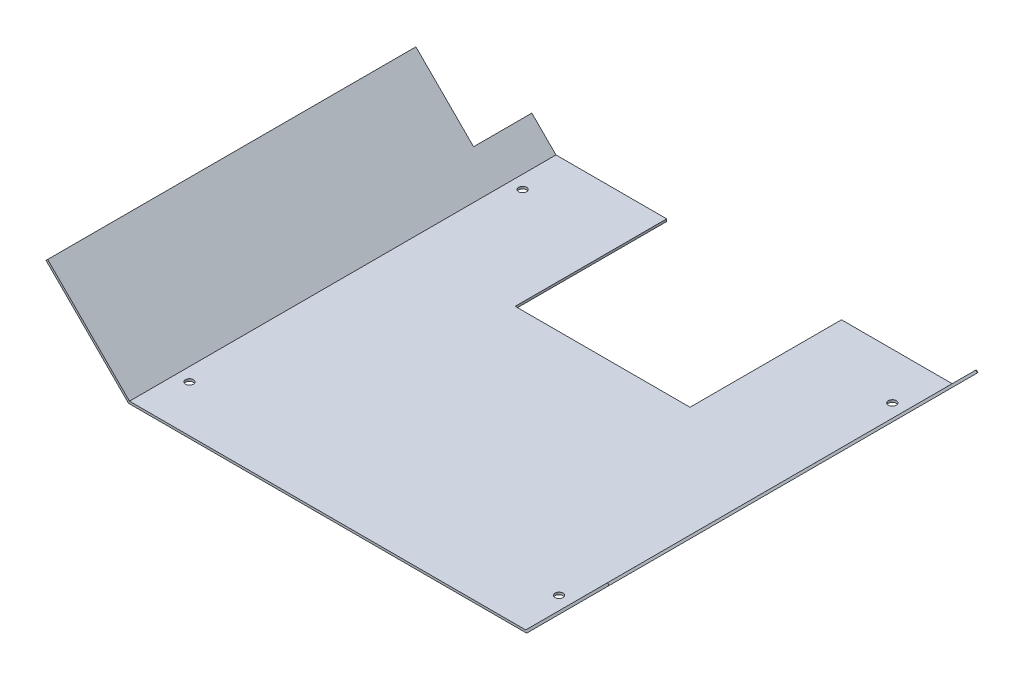
from build123d import *

# Parameters (mm, degrees)
EXTRU_MINCE1_DEPTH      = 183
ESQUISSE8_W             = 75
ESQUISSE8_H             = 65
ENL_V_MAT_EXTRU_2_DEPTH = 1
D_GAGEMENT_M32_D        = 3.4
ENL_V_MAT_EXTRU_3_REACH = 173.369
ESQUISSE15_W            = 25
ESQUISSE15_H            = 35
ENL_V_MAT_EXTRU_4_REACH = 173.364
ESQUISSE16_W            = 35
ESQUISSE16_H            = 25


with BuildPart() as part:
    # Esquisse2 → Extru.-Mince1 (new body)
    with BuildSketch(Plane.XY):
        Polygon((-59.170699115, 35.114), (-24.057682042, 0), (145.942317958, 0), (181.056317958, 35.113017073), (181.763414842, 34.405900395), (146.356523321, -1), (-24.471903803, -1), (-59.877815794, 34.406903116), align=None)
    extrude(amount=EXTRU_MINCE1_DEPTH)

    # Esquisse8 → Enlèv. mat.-Extru.2 (cut)
    with BuildSketch(Plane(origin=(0, 0, 0), x_dir=(1, 0, 0), z_dir=(0, 1, 0))):
        with Locations((60.942317958, -32.5)):
            Rectangle(ESQUISSE8_W, ESQUISSE8_H)
    extrude(amount=-ENL_V_MAT_EXTRU_2_DEPTH, mode=Mode.SUBTRACT)

    # Dégagement M32 (through all)
    with Locations(Plane(origin=(0, 0, 0), x_dir=(-1, 0, 0), z_dir=(0, 1, 0))):
        with Locations((18.357682042, 20), (-140.242317958, 20), (-140.242317958, 163), (18.357682042, 163)):
            Hole(D_GAGEMENT_M32_D / 2)

    # Esquisse15 → Enlèv. mat.-Extru.3 (cut, up to next)
    with BuildSketch(Plane(origin=(-12.73629442, -12.7359379, 0), x_dir=(0, 0, 1), z_dir=(-0.707116678, -0.707096884, 0)), mode=Mode.PRIVATE) as enl_v_mat_extru_3_sk1:
        with Locations((12.5, 49.169112012)):
            Rectangle(ESQUISSE15_W, ESQUISSE15_H)
    enl_v_mat_extru_3_tool1 = extrude(enl_v_mat_extru_3_sk1.sketch, amount=-ENL_V_MAT_EXTRU_3_REACH, mode=Mode.PRIVATE) & part.part
    add(enl_v_mat_extru_3_tool1.solids().sort_by_distance((-47.50362, 22.032361, 12.5))[0], mode=Mode.SUBTRACT)

    # Esquisse16 → Enlèv. mat.-Extru.4 (cut, up to next)
    with BuildSketch(Plane(origin=(73.676213194, -73.678275628, 0), x_dir=(0.707116678, 0.707096884, 0), z_dir=(0.707096884, -0.707116678, 0)), mode=Mode.PRIVATE) as enl_v_mat_extru_4_sk1:
        with Locations((135.356247065, 12.5)):
            Rectangle(ESQUISSE16_W, ESQUISSE16_H)
    enl_v_mat_extru_4_tool1 = extrude(enl_v_mat_extru_4_sk1.sketch, amount=-ENL_V_MAT_EXTRU_4_REACH, mode=Mode.PRIVATE) & part.part
    add(enl_v_mat_extru_4_tool1.solids().sort_by_distance((169.388873, 22.031705, 12.5))[0], mode=Mode.SUBTRACT)


solid = part.part
